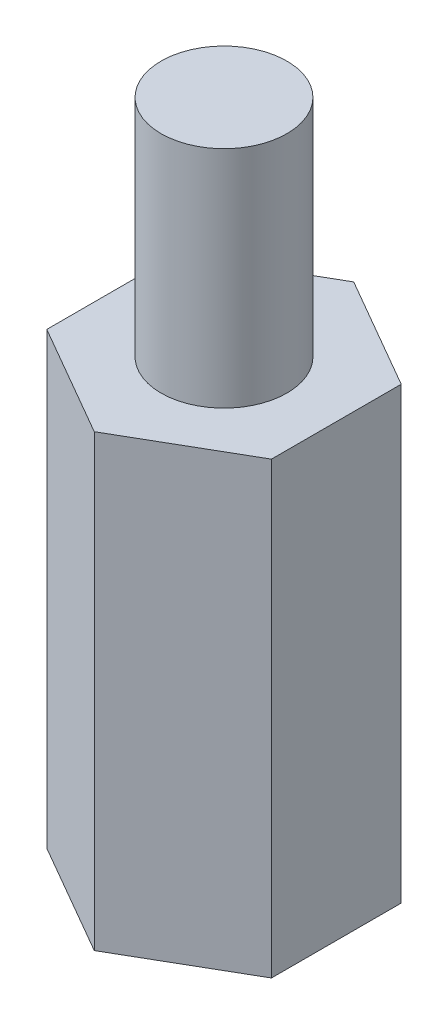
from build123d import *

# Parameters (mm, degrees)
BOSS_EXTRUDE1_DEPTH = 12.7
SKETCH2_R           = 1.778
BOSS_EXTRUDE2_DEPTH = 6.35


with BuildPart() as part:
    # Sketch1 → Boss-Extrude1 (new body)
    with BuildSketch(Plane(origin=(0, 0, 0), x_dir=(1, 0, 0), z_dir=(0, 1, 0))):
        Polygon((0, 3.666174209), (-3.175, 1.833087105), (-3.175, -1.833087105), (0, -3.666174209), (3.175, -1.833087105), (3.175, 1.833087105), align=None)
    extrude(amount=BOSS_EXTRUDE1_DEPTH)

    # Sketch2 → Boss-Extrude2 (add)
    with BuildSketch(Plane(origin=(0, 12.7, 0), x_dir=(1, 0, 0), z_dir=(0, 1, 0))):
        Circle(SKETCH2_R)
    extrude(amount=BOSS_EXTRUDE2_DEPTH)


solid = part.part
